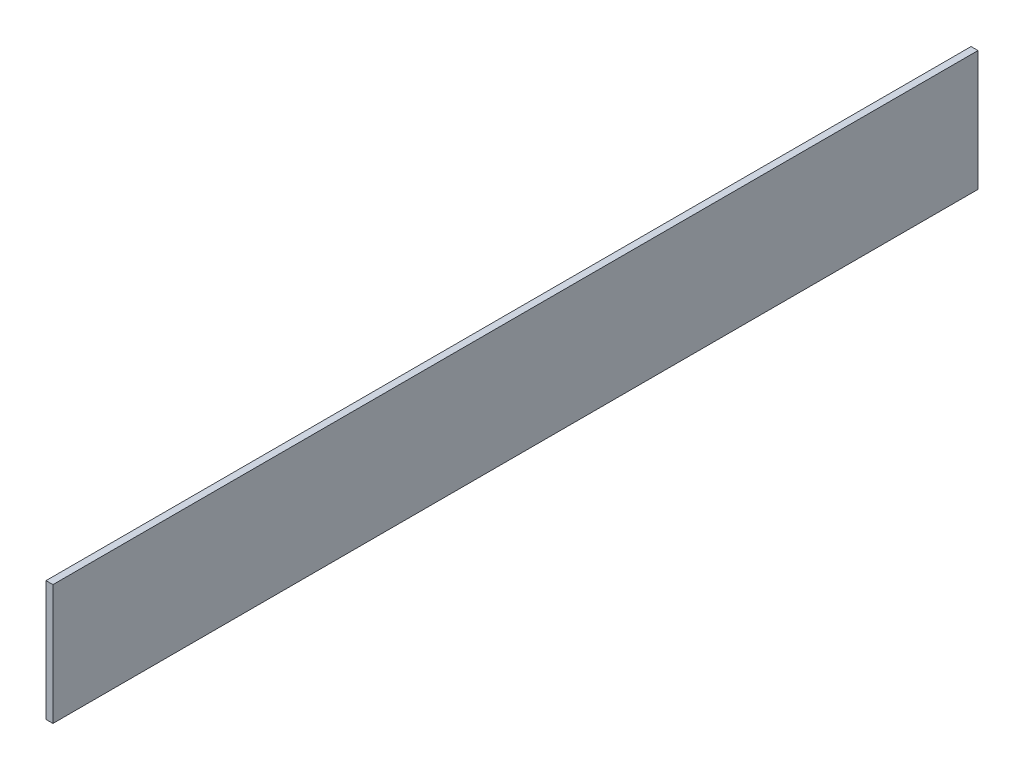
from build123d import *

# Parameters (mm, degrees)
SKETCH1_W           = 4.7625
SKETCH1_H           = 82.55
BOSS_EXTRUDE1_DEPTH = 635


with BuildPart() as part:
    # Sketch1 → Boss-Extrude1 (new body)
    with BuildSketch(Plane.XY):
        with Locations((2.38125, 41.275)):
            Rectangle(SKETCH1_W, SKETCH1_H)
    extrude(amount=BOSS_EXTRUDE1_DEPTH)


solid = part.part
